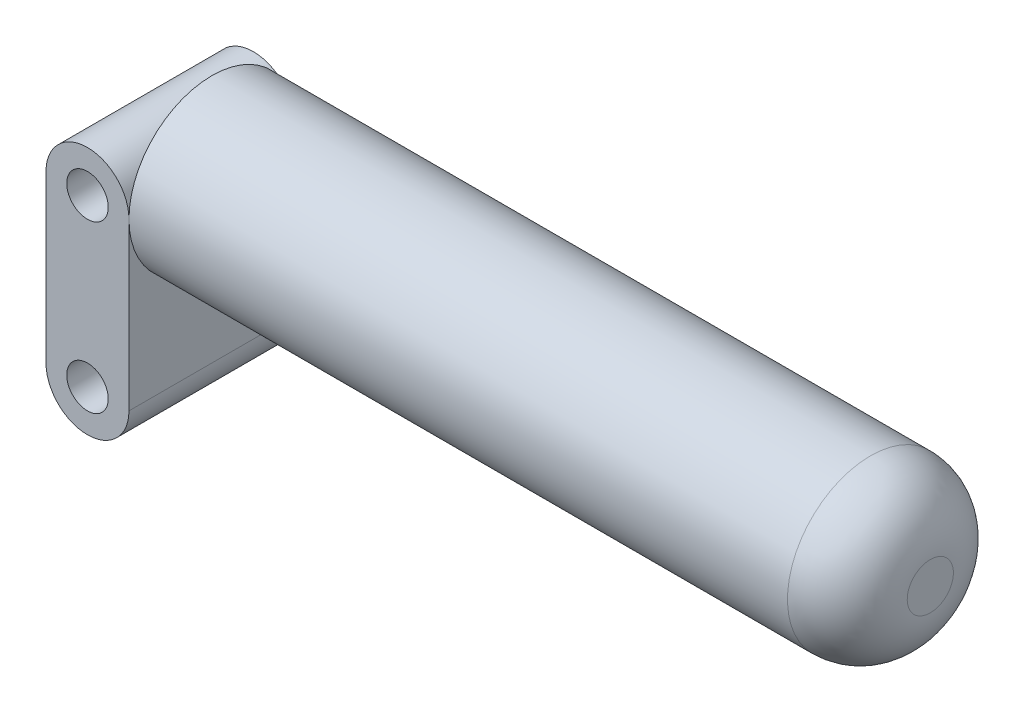
from build123d import *

# Parameters (mm, degrees)
ESQUISSE1_R        = 2.5
BOSS_EXTRU_1_DEPTH = 10
ESQUISSE2_R        = 10
BOSS_EXTRU_2_DEPTH = 86.6
CONG_1_R           = 7.216666667


with BuildPart() as part:
    # Esquisse1 → Boss.-Extru.1 (new, symmetric)
    with BuildSketch(Plane.XY):
        with BuildLine():
            Line((5, 10), (5, -10))
            ThreePointArc((5, -10), (0, -15), (-5, -10))
            Line((-5, -10), (-5, 10))
            ThreePointArc((-5, 10), (0, 15), (5, 10))
        make_face()
        with Locations((0, 10)):
            Circle(ESQUISSE1_R, mode=Mode.SUBTRACT)
        with Locations((0, -10)):
            Circle(ESQUISSE1_R, mode=Mode.SUBTRACT)
    extrude(amount=BOSS_EXTRU_1_DEPTH, both=True)

    # Esquisse2 → Boss.-Extru.2 (add)
    with BuildSketch(Plane(origin=(5, 0, 0), x_dir=(0, 0, -1), z_dir=(1, 0, 0))):
        with Locations((0, 10)):
            Circle(ESQUISSE2_R)
    extrude(amount=BOSS_EXTRU_2_DEPTH)

    # Congé1
    cong_1_edges = [part.edges().sort_by_distance(p)[0] for p in [
        (91.6, 10, 10),
    ]]
    fillet(cong_1_edges, radius=CONG_1_R)


solid = part.part
